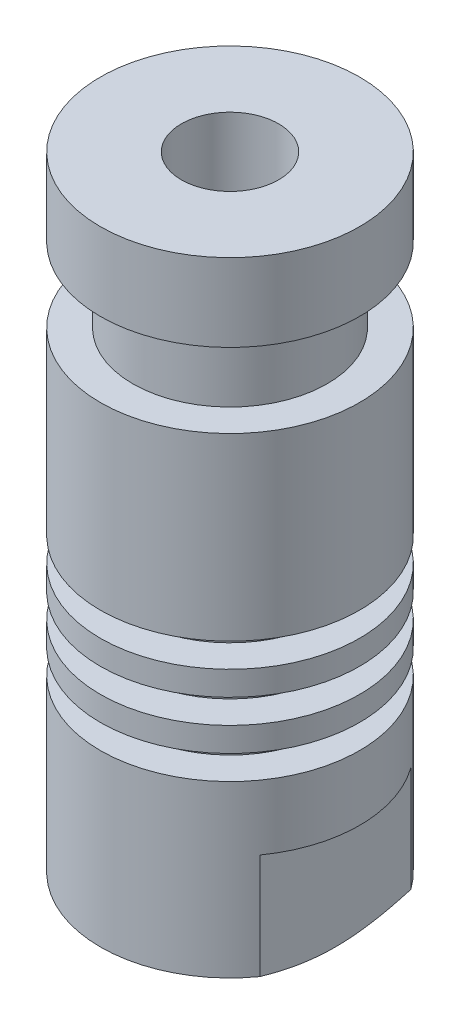
from build123d import *

# Parameters (mm, degrees)
TAGLIO_ESTRUSIONE1_REACH             = 10
SCHIZZO2_W                           = 1.5
SCHIZZO2_H                           = 8
TAGLIO_ESTRUSIONE1_DIRECTION_2_REACH = 10
SCHIZZO7_R                           = 3
TAGLIO_ESTRUSIONE2_DEPTH             = 41
FORO_FILETTATO_M8_1_D                = 6.8
FORO_FILETTATO_M8_1_DEPTH            = 12
FORO_FILETTATO_M8_1_TIP              = 2.042926105


with BuildPart() as part:
    # Schizzo1 → Rivoluzione1 (revolve)
    with BuildSketch(Plane.XY):
        Polygon((0, 0), (-5, 0), (-8, 1.5), (-8, 12), (-6, 12), (-6, 13.5), (-8, 13.5), (-8, 15), (-6, 15), (-6, 16.5), (-8, 16.5), (-8, 18), (-6, 18), (-6, 19.5), (-8, 19.5), (-8, 30.6), (-6, 30.6), (-6, 35.2), (-8, 35.2), (-8, 40), (0, 40), align=None)
    revolve(axis=Axis((0, 129.407380346, 0), (0, -1, 0)))

    # Schizzo2 → Taglio-Estrusione1 (cut, up to next)
    with BuildSketch(Plane.XY, mode=Mode.PRIVATE) as taglio_estrusione1_sk1:
        with Locations((-7.25, 4)):
            Rectangle(SCHIZZO2_W, SCHIZZO2_H)
    taglio_estrusione1_tool1 = extrude(taglio_estrusione1_sk1.sketch, amount=-TAGLIO_ESTRUSIONE1_REACH, mode=Mode.PRIVATE) & part.part
    add(taglio_estrusione1_tool1.solids().sort_by_distance((-7.25, 4, 0))[0], mode=Mode.SUBTRACT)
    # Schizzo2 → Taglio-Estrusione1 (cut, up to next)
    with BuildSketch(Plane.XY, mode=Mode.PRIVATE) as taglio_estrusione1_sk2:
        with Locations((7.25, 4)):
            Rectangle(SCHIZZO2_W, SCHIZZO2_H)
    taglio_estrusione1_tool2 = extrude(taglio_estrusione1_sk2.sketch, amount=-TAGLIO_ESTRUSIONE1_REACH, mode=Mode.PRIVATE) & part.part
    add(taglio_estrusione1_tool2.solids().sort_by_distance((7.25, 4, 0))[0], mode=Mode.SUBTRACT)

    # Schizzo2 → Taglio-Estrusione1 direction 2 (cut, up to next)
    with BuildSketch(Plane.XY, mode=Mode.PRIVATE) as taglio_estrusione1_direction_2_sk1:
        with Locations((-7.25, 4)):
            Rectangle(SCHIZZO2_W, SCHIZZO2_H)
    taglio_estrusione1_direction_2_tool1 = extrude(taglio_estrusione1_direction_2_sk1.sketch, amount=TAGLIO_ESTRUSIONE1_DIRECTION_2_REACH, mode=Mode.PRIVATE) & part.part
    add(taglio_estrusione1_direction_2_tool1.solids().sort_by_distance((-7.25, 4, 0))[0], mode=Mode.SUBTRACT)
    # Schizzo2 → Taglio-Estrusione1 direction 2 (cut, up to next)
    with BuildSketch(Plane.XY, mode=Mode.PRIVATE) as taglio_estrusione1_direction_2_sk2:
        with Locations((7.25, 4)):
            Rectangle(SCHIZZO2_W, SCHIZZO2_H)
    taglio_estrusione1_direction_2_tool2 = extrude(taglio_estrusione1_direction_2_sk2.sketch, amount=TAGLIO_ESTRUSIONE1_DIRECTION_2_REACH, mode=Mode.PRIVATE) & part.part
    add(taglio_estrusione1_direction_2_tool2.solids().sort_by_distance((7.25, 4, 0))[0], mode=Mode.SUBTRACT)

    # Schizzo7 → Taglio-Estrusione2 (cut, through all)
    with BuildSketch(Plane(origin=(0, 40, 0), x_dir=(1, 0, 0), z_dir=(0, 1, 0))):
        Circle(SCHIZZO7_R)
    extrude(amount=-TAGLIO_ESTRUSIONE2_DEPTH, mode=Mode.SUBTRACT)

    # Foro filettato M8-1
    with Locations(Plane(origin=(0, 0, 0), x_dir=(-1, 0, 0), z_dir=(0, -1, 0))):
        with Locations((0, 0)):
            Hole(FORO_FILETTATO_M8_1_D / 2, depth=FORO_FILETTATO_M8_1_DEPTH)
            with Locations((0, 0, -(FORO_FILETTATO_M8_1_DEPTH + FORO_FILETTATO_M8_1_TIP / 2))):  # 118° drill point
                Cone(0, FORO_FILETTATO_M8_1_D / 2, FORO_FILETTATO_M8_1_TIP, mode=Mode.SUBTRACT)


solid = part.part
